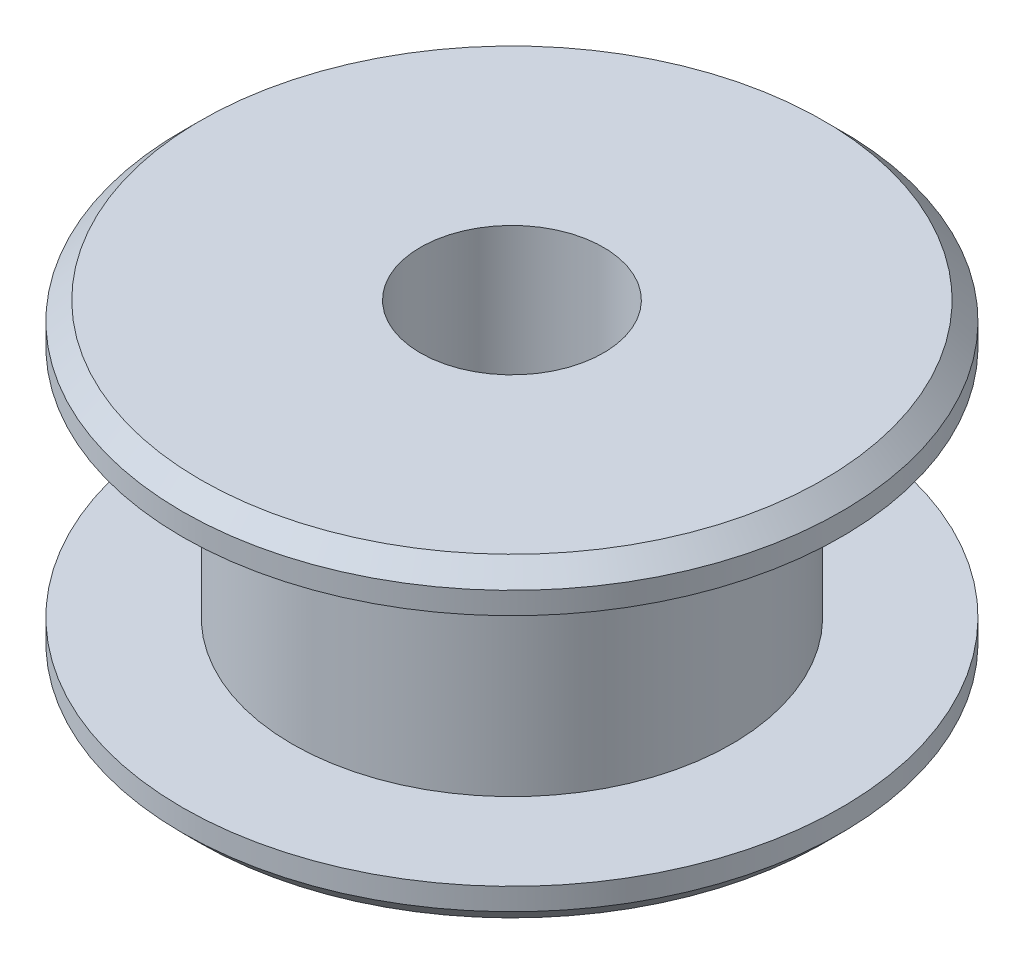
from build123d import *

# Parameters (mm, degrees)
SKETCH_1_R          = 9
EXTRUDE_1_DEPTH     = 1.1
SKETCH_2_R          = 6
EXTRUDE_2_DEPTH     = 6.4
SKETCH_3_R          = 9
EXTRUDE_3_DEPTH     = 1.1
CHAMFER_1_SIZE      = 0.5
SKETCH_4_R          = 2.5
CUT_EXTRUDE_1_DEPTH = 9.6


with BuildPart() as part:
    # 草图1 → 凸台-拉伸1 (new body)
    with BuildSketch(Plane(origin=(0, 0, 0), x_dir=(1, 0, 0), z_dir=(0, 1, 0))):
        Circle(SKETCH_1_R)
    extrude(amount=EXTRUDE_1_DEPTH)

    # 草图2 → 凸台-拉伸2 (add)
    with BuildSketch(Plane(origin=(0, 1.1, 0), x_dir=(1, 0, 0), z_dir=(0, 1, 0))):
        Circle(SKETCH_2_R)
    extrude(amount=EXTRUDE_2_DEPTH)

    # 草图3 → 凸台-拉伸3 (add)
    with BuildSketch(Plane(origin=(0, 7.5, 0), x_dir=(1, 0, 0), z_dir=(0, 1, 0))):
        Circle(SKETCH_3_R)
    extrude(amount=EXTRUDE_3_DEPTH)

    # 倒角1
    chamfer_1_edges = [part.edges().sort_by_distance(p)[0] for p in [
        (-9, 0, 0),
        (-9, 8.6, 0),
    ]]
    chamfer(chamfer_1_edges, length=CHAMFER_1_SIZE)

    # 草图4 → 切除-拉伸1 (cut, through all)
    with BuildSketch(Plane(origin=(0, 8.6, 0), x_dir=(1, 0, 0), z_dir=(0, 1, 0))):
        Circle(SKETCH_4_R)
    extrude(amount=-CUT_EXTRUDE_1_DEPTH, mode=Mode.SUBTRACT)


solid = part.part
